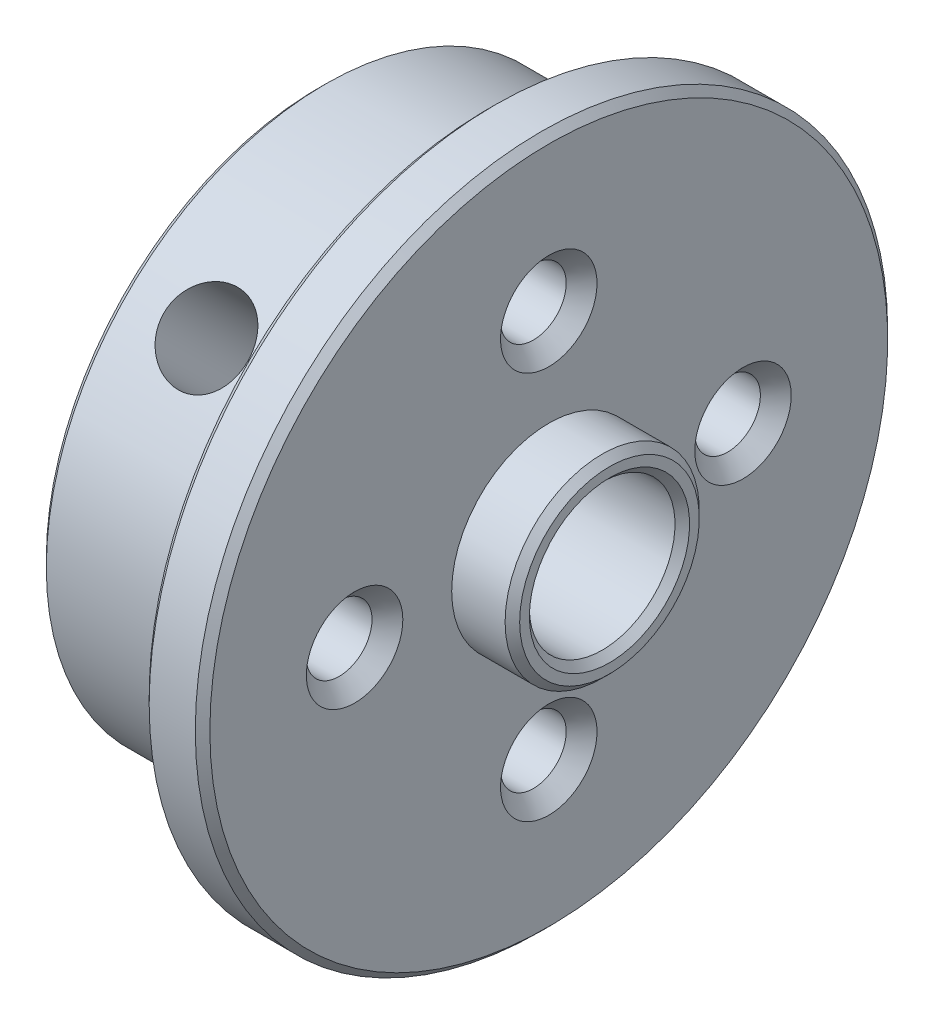
from build123d import *

# Parameters (mm, degrees)
F_6_32_TAPPED_HOLE1_AT_2_COUNT = 2
F_6_32_TAPPED_HOLE1_AT_2_PITCH = 11.313708499
F_6_32_TAPPED_HOLE1_AT_3_COUNT = 2
F_6_32_TAPPED_HOLE1_AT_3_PITCH = 11.313708499
F_6_32_TAPPED_HOLE1_AT_4_COUNT = 2
F_6_32_TAPPED_HOLE1_AT_4_PITCH = 16
BOSS_EXTRUDE1_START            = 10
SKETCH4_R                      = 1.25
BOSS_EXTRUDE1_DEPTH            = 1.5
F_8_32_TAPPED_HOLE1_D          = 3.4544
F_8_32_TAPPED_HOLE1_DEPTH      = 10.708
F_8_32_TAPPED_HOLE1_TIP        = 1.037806461
CHAMFER1_SIZE                  = 0.3


with BuildPart() as part:
    # Sketch1 → Revolve1 (revolve)
    with BuildSketch(Plane.XY):
        Polygon((-9.5, 3), (2.5, 3), (2.5, 4), (0, 4), (0, 14.2621), (-2.5, 14.2621), (-2.5, 11.5), (-9.5, 11.5), align=None)
    revolve(axis=Axis((0, 0, 0), (1, 0, 0)))

    # Sketch3 → 6-32 Tapped Hole1 (revolve, cut)
    with BuildSketch(Plane(origin=(0, 0, 8), x_dir=(0, 0, -1), z_dir=(0, 1, 0))):
        Polygon((0, 0), (0, 9.5), (1.98755, 9.5), (1.35255, 8.865), (1.35255, 0.635), (1.98755, 0), align=None)
    f_6_32_tapped_hole1 = revolve(axis=Axis((6.35, 0, 8), (-1, 0, 0)), mode=Mode.SUBTRACT)

    # 6-32 Tapped Hole1 at 2: 6-32 Tapped Hole1 ×2
    with Locations(*[Vector(0, 0.7071067811865476, -0.7071067811865476) * (i * F_6_32_TAPPED_HOLE1_AT_2_PITCH) for i in range(1, F_6_32_TAPPED_HOLE1_AT_2_COUNT)]):
        add(f_6_32_tapped_hole1, mode=Mode.SUBTRACT)

    # 6-32 Tapped Hole1 at 3: 6-32 Tapped Hole1 ×2
    with Locations(*[Vector(0, -0.7071067811865476, -0.7071067811865476) * (i * F_6_32_TAPPED_HOLE1_AT_3_PITCH) for i in range(1, F_6_32_TAPPED_HOLE1_AT_3_COUNT)]):
        add(f_6_32_tapped_hole1, mode=Mode.SUBTRACT)

    # 6-32 Tapped Hole1 at 4: 6-32 Tapped Hole1 ×2
    with Locations(*[(0, 0, -i * F_6_32_TAPPED_HOLE1_AT_4_PITCH) for i in range(1, F_6_32_TAPPED_HOLE1_AT_4_COUNT)]):
        add(f_6_32_tapped_hole1, mode=Mode.SUBTRACT)

    # Sketch4 → Boss-Extrude1 (add)
    with BuildSketch(Plane(origin=(0, 0, 0), x_dir=(-1, 0, 0), z_dir=(0, 0.7071067811865464, 0.7071067811865488)).offset(BOSS_EXTRUDE1_START)):
        with Locations((6, 0)):
            Circle(SKETCH4_R)
    extrude(amount=BOSS_EXTRUDE1_DEPTH)

    # 8-32 Tapped Hole1
    with Locations(Plane(origin=(0, 8.131727984, 8.131727984), x_dir=(1, 0, 0), z_dir=(0, 0.7071067811865465, 0.7071067811865487))):
        with Locations((-6, 0)):
            Hole(F_8_32_TAPPED_HOLE1_D / 2, depth=F_8_32_TAPPED_HOLE1_DEPTH)
            with Locations((0, 0, -(F_8_32_TAPPED_HOLE1_DEPTH + F_8_32_TAPPED_HOLE1_TIP / 2))):  # 118° drill point
                Cone(0, F_8_32_TAPPED_HOLE1_D / 2, F_8_32_TAPPED_HOLE1_TIP, mode=Mode.SUBTRACT)

    # Chamfer1
    chamfer1_edges = [part.edges().sort_by_distance(p)[0] for p in [
        (-9.5, -11.5, 0),
        (-2.5, -14.2621, 0),
        (0, -14.2621, 0),
        (2.5, -3, 0),
        (2.5, -4, 0),
        (-9.5, -3, 0),
    ]]
    chamfer(chamfer1_edges, length=CHAMFER1_SIZE)


solid = part.part
